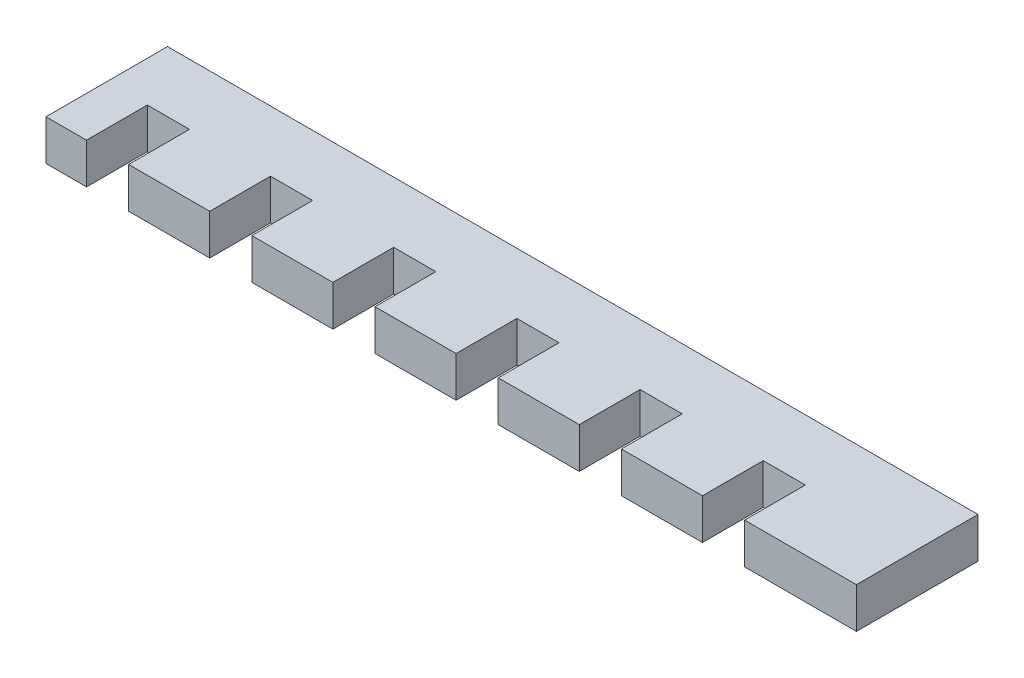
from build123d import *

# Parameters (mm, degrees)
SKETCH1_W           = 100
SKETCH1_H           = 15
BOSS_EXTRUDE1_DEPTH = 5
SKETCH2_W           = 5.2
SKETCH2_H           = 7.5
CUT_EXTRUDE1_DEPTH  = 5


with BuildPart() as part:
    # Sketch1 → Boss-Extrude1 (new body)
    with BuildSketch(Plane(origin=(0, 0, 0), x_dir=(1, 0, 0), z_dir=(0, 1, 0))):
        Rectangle(SKETCH1_W, SKETCH1_H)
    extrude(amount=BOSS_EXTRUDE1_DEPTH)

    # Sketch2 → Cut-Extrude1 (cut)
    with BuildSketch(Plane(origin=(0, 0, 0), x_dir=(1, 0, 0), z_dir=(0, 1, 0))):
        with Locations((-42.4, -3.75)):
            Rectangle(SKETCH2_W, SKETCH2_H)
        with Locations((-27.2, -3.75)):
            Rectangle(SKETCH2_W, SKETCH2_H)
        with Locations((-12, -3.75)):
            Rectangle(SKETCH2_W, SKETCH2_H)
        with Locations((3.2, -3.75)):
            Rectangle(SKETCH2_W, SKETCH2_H)
        with Locations((18.4, -3.75)):
            Rectangle(SKETCH2_W, SKETCH2_H)
        with Locations((33.6, -3.75)):
            Rectangle(SKETCH2_W, SKETCH2_H)
    extrude(amount=CUT_EXTRUDE1_DEPTH, mode=Mode.SUBTRACT)


solid = part.part
